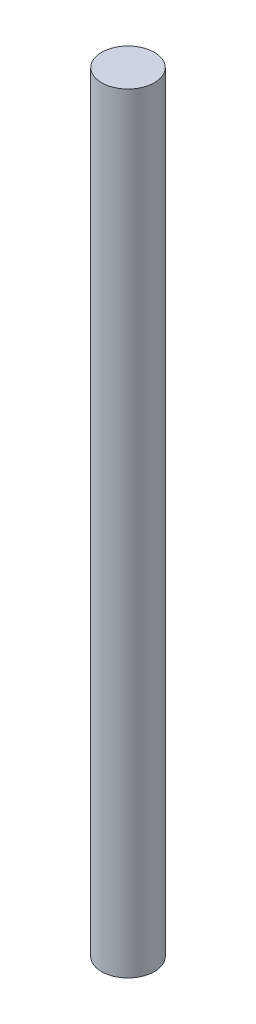
from build123d import *

# Parameters (mm, degrees)
SKETCH1_R      = 2.5
EXTRUDE1_DEPTH = 73


with BuildPart() as part:
    # Sketch1 → Extrude1 (new body)
    with BuildSketch(Plane(origin=(0, 0, 0), x_dir=(1, 0, 0), z_dir=(0, 1, 0))):
        Circle(SKETCH1_R)
    extrude(amount=EXTRUDE1_DEPTH)


solid = part.part
